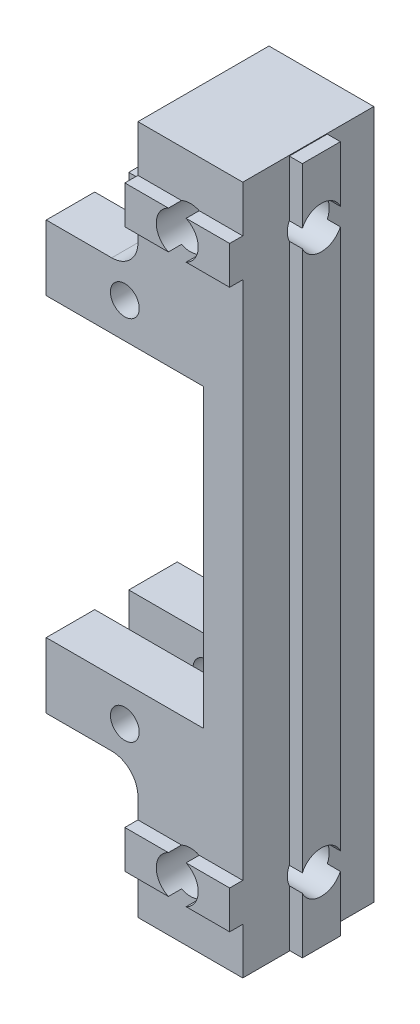
from build123d import *

# Parameters (mm, degrees)
SKETCH1_R                      = 1.1
MAIN_DEPTH                     = 5
SKETCH2_W                      = 1
SKETCH2_H                      = 2.9
MAKERBEAMSUPPORT_DEPTH         = 26.25
SKETCH3_R                      = 1.6
MAKERBEAMHOLES_DEPTH           = 10
SKETCH4_W                      = 2.6
SKETCH4_H                      = 32.6
CUT_EXTRUDE2_DEPTH             = 12
SKETCH5_W                      = 8
SKETCH5_H                      = 2.9
MAKERBEAMTOPSUPPORT_DEPTH      = 1
SKETCH6_R                      = 1.6
MAKERBEAMTOPHOLESSUPPORT_DEPTH = 12
FILLET1_R                      = 2


with BuildPart() as part:
    # Sketch1 → Main (new body, symmetric)
    with BuildSketch(Plane.XY):
        Polygon((0, 11.3), (-12, 11.3), (-12, 16.3), (-5, 16.3), (-5, 26.3), (3, 26.3), (3, -26.3), (-5, -26.3), (-5, -16.3), (-12, -16.3), (-12, -11.3), (0, -11.3), align=None)
        with Locations((-6, 14)):
            Circle(SKETCH1_R, mode=Mode.SUBTRACT)
        with Locations((-6, -14)):
            Circle(SKETCH1_R, mode=Mode.SUBTRACT)
    extrude(amount=MAIN_DEPTH, both=True)

    # Sketch2 → MakerBeamSupport (add, symmetric)
    with BuildSketch(Plane(origin=(0, 0, 0), x_dir=(1, 0, 0), z_dir=(0, 1, 0))):
        with Locations((3.5, 0)):
            Rectangle(SKETCH2_W, SKETCH2_H)
    extrude(amount=MAKERBEAMSUPPORT_DEPTH, both=True)

    # Sketch3 → MakerBeamHoles (cut, through all)
    with BuildSketch(Plane.ZY.offset(5)):
        with Locations((0, 21.3)):
            Circle(SKETCH3_R)
        with Locations((0, -21.3)):
            Circle(SKETCH3_R)
    extrude(amount=-MAKERBEAMHOLES_DEPTH, mode=Mode.SUBTRACT)

    # Sketch4 → Cut-Extrude2 (cut)
    with BuildSketch(Plane.ZY.offset(12)):
        Rectangle(SKETCH4_W, SKETCH4_H)
    extrude(amount=-CUT_EXTRUDE2_DEPTH, mode=Mode.SUBTRACT)

    # Sketch5 → MakerBeamTopSupport (add)
    with BuildSketch(Plane(origin=(0, 0, 5), x_dir=(-1, 0, 0), z_dir=(0, 0, -1))):
        with Locations((1, 21.3)):
            Rectangle(SKETCH5_W, SKETCH5_H)
        with Locations((1, -21.3)):
            Rectangle(SKETCH5_W, SKETCH5_H)
    extrude(amount=-MAKERBEAMTOPSUPPORT_DEPTH)

    # Sketch6 → MakerBeamTopHolesSupport (cut, through all)
    with BuildSketch(Plane.XY.offset(6)):
        with Locations((-1, 21.3)):
            Circle(SKETCH6_R)
        with Locations((-1, -21.3)):
            Circle(SKETCH6_R)
    extrude(amount=-MAKERBEAMTOPHOLESSUPPORT_DEPTH, mode=Mode.SUBTRACT)

    # Fillet1
    fillet1_edges = [part.edges().sort_by_distance(p)[0] for p in [
        (-5, 16.3, 3.15),
        (-5, -16.3, 3.15),
        (-5, 16.3, -3.15),
        (-5, -16.3, -3.15),
    ]]
    fillet(fillet1_edges, radius=FILLET1_R)


solid = part.part
